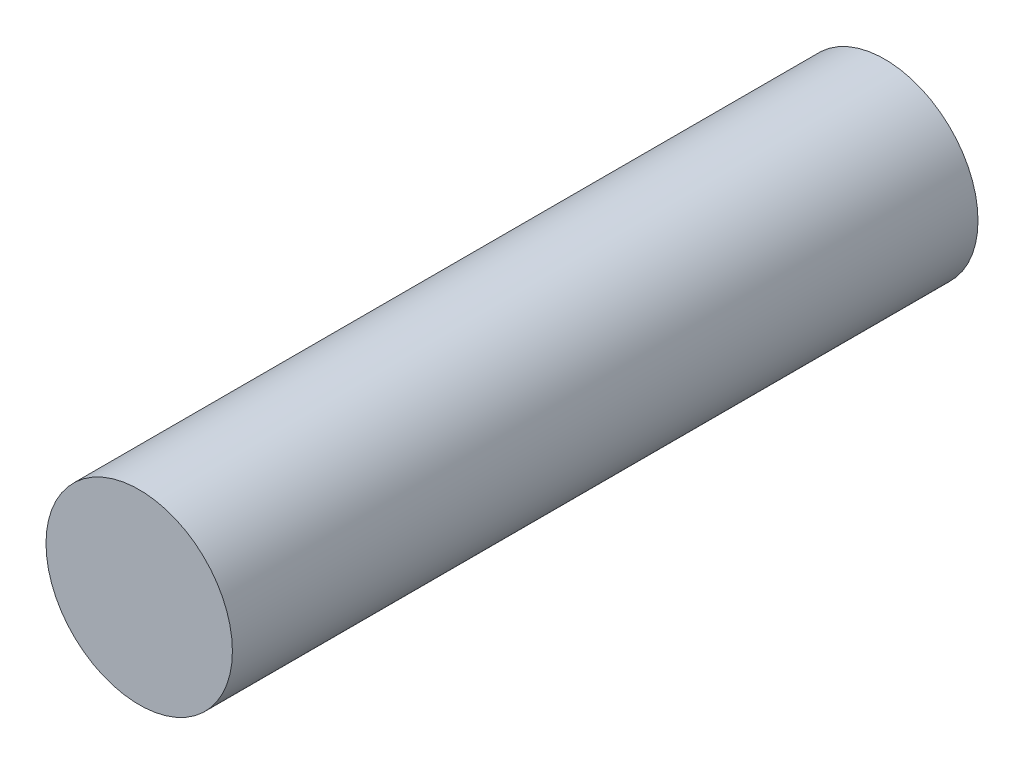
from build123d import *

# Parameters (mm, degrees)
SKETCH1_R           = 6.35
BOSS_EXTRUDE1_DEPTH = 50.8


with BuildPart() as part:
    # Sketch1 → Boss-Extrude1 (new body)
    with BuildSketch(Plane.XY):
        Circle(SKETCH1_R)
    extrude(amount=BOSS_EXTRUDE1_DEPTH)


solid = part.part
